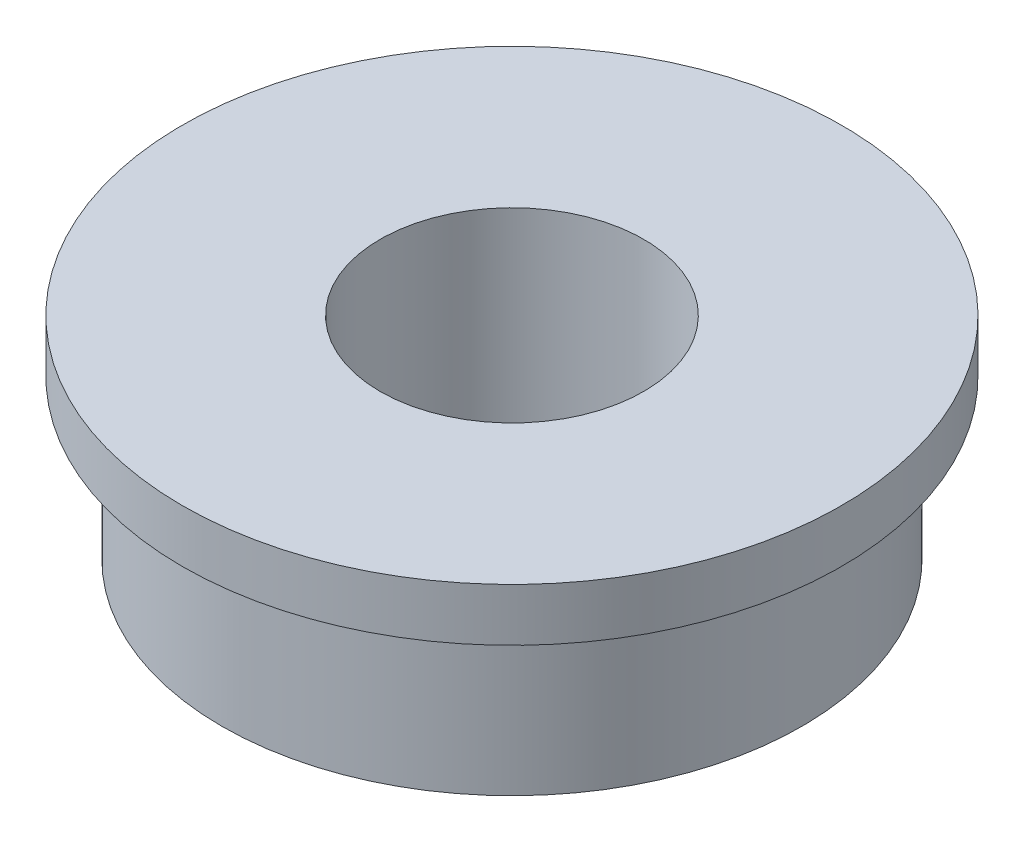
from build123d import *


with BuildPart() as part:
    # Sketch1 → Revolve1 (revolve)
    with BuildSketch(Plane(origin=(0, 0, 0), x_dir=(0, 0, -1), z_dir=(1, 0, 0))):
        Polygon((2.5, 0), (5.5, 0), (5.5, 3), (6.25, 3), (6.25, 4), (2.5, 4), align=None)
    revolve(axis=Axis((0, 9.329589921, 0), (0, -1, 0)))


solid = part.part
